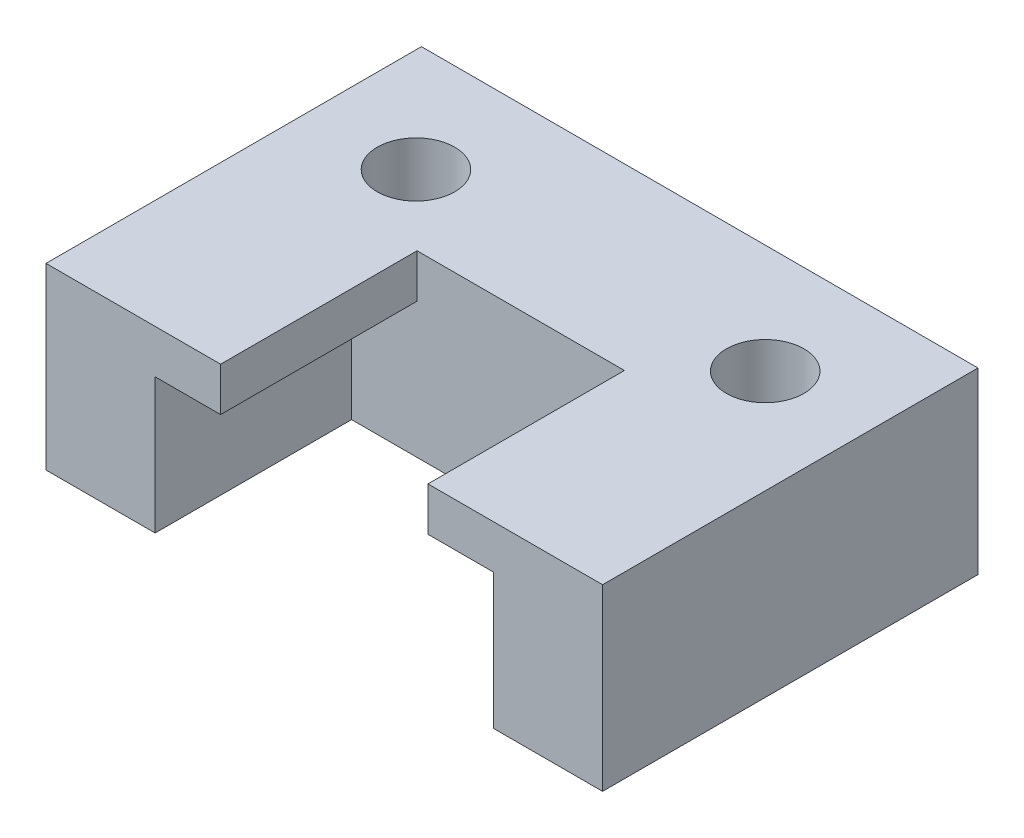
from build123d import *

# Parameters (mm, degrees)
SKETCH1_R           = 1.775
BOSS_EXTRUDE1_DEPTH = 6.2
BOSS_EXTRUDE2_START = 6.2
SKETCH1_3_R         = 1.775
BOSS_EXTRUDE2_DEPTH = 2


with BuildPart() as part:
    # Sketch1 → Boss-Extrude1 (new body)
    with BuildSketch(Plane(origin=(0, 0, 0), x_dir=(1, 0, 0), z_dir=(0, 1, 0))):
        Polygon((-12.75, 5), (12.75, 5), (12.75, -12.2), (7.75, -12.2), (7.75, -3.2), (-7.75, -3.2), (-7.75, -12.2), (-12.75, -12.2), align=None)
        with Locations(Location((-8, 0, 0), (0, 0, 90))):
            Circle(SKETCH1_R, mode=Mode.SUBTRACT)
        with Locations(Location((8, 0, 0), (0, 0, 90))):
            Circle(SKETCH1_R, mode=Mode.SUBTRACT)
    extrude(amount=BOSS_EXTRUDE1_DEPTH)

    # Sketch1_3 → Boss-Extrude2 (add)
    with BuildSketch(Plane(origin=(0, 0, 0), x_dir=(1, 0, 0), z_dir=(0, 1, 0)).offset(BOSS_EXTRUDE2_START)):
        Polygon((12.75, 5), (-12.75, 5), (-12.75, -12.2), (-4.75, -12.2), (-4.75, -3.2), (4.75, -3.2), (4.75, -12.2), (12.75, -12.2), align=None)
        with Locations(Location((-8, 0, 0), (0, 0, 90))):
            Circle(SKETCH1_3_R, mode=Mode.SUBTRACT)
        with Locations(Location((8, 0, 0), (0, 0, 90))):
            Circle(SKETCH1_3_R, mode=Mode.SUBTRACT)
    extrude(amount=BOSS_EXTRUDE2_DEPTH)


solid = part.part
